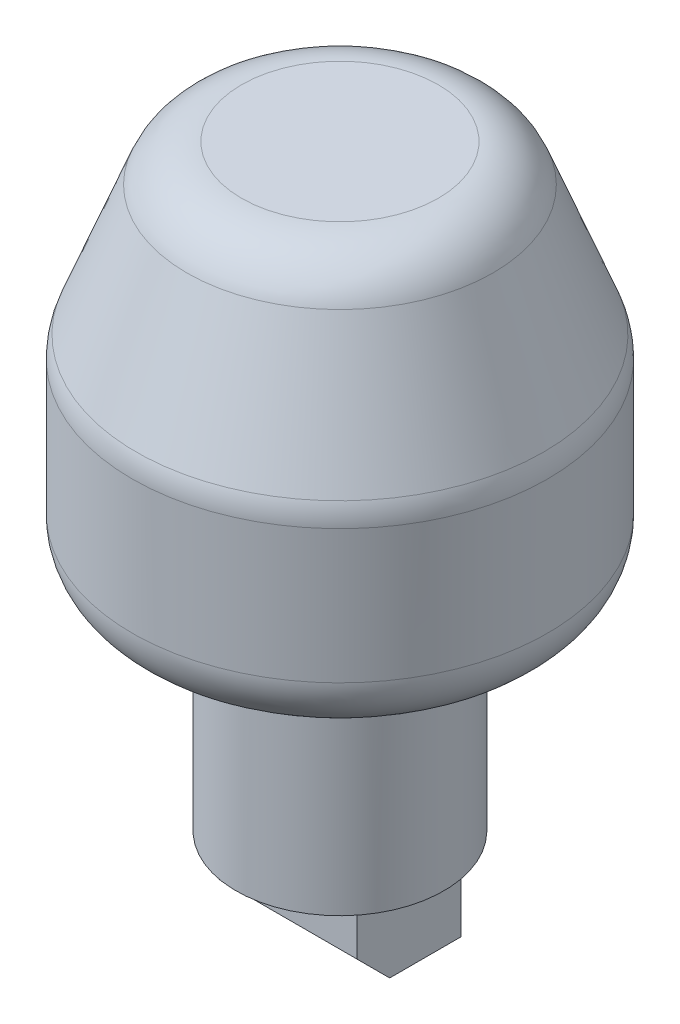
from build123d import *

# Parameters (mm, degrees)
FILLET2_R                = 6.35
BOSS_EXTRUDE1_DEPTH      = 7.4549
SKETCH3_W                = 4.78028
SKETCH3_H                = 7.4422
SKETCH3_W_2              = 4.84124
CUT_EXTRUDE1_DEPTH       = 2.54
BOSS_EXTRUDE2_REACH      = 88.307
BOSS_EXTRUDE2_END_RADIUS = 11.2395
BOSS_EXTRUDE2_START      = 14.29512
SKETCH4_W                = 3.556
SKETCH4_H                = 2.1844


with BuildPart() as part:
    # Sketch1 → Revolve1 (revolve)
    with BuildSketch(Plane.XY):
        Polygon((0, 0), (11.2395, 0), (11.2395, 23.4188), (22.473370688, 23.4188), (22.473370688, 45.4152), (14.986, 64.619312752), (0, 64.619312752), align=None)
    revolve(axis=Axis((0, 64.619312752, 0), (0, -1, 0)))

    # Fillet2
    fillet2_edges = [part.edges().sort_by_distance(p)[0] for p in [
        (-22.473370688, 23.4188, 0),
        (-22.473370688, 45.4152, 0),
        (-14.986, 64.619312752, 0),
    ]]
    fillet(fillet2_edges, radius=FILLET2_R)

    # Sketch2 → Boss-Extrude1 (add, symmetric)
    with BuildSketch(Plane(origin=(0, 0, 0), x_dir=(0, 0, -1), z_dir=(1, 0, 0))):
        Polygon((5.626190712, 0), (-5.626190712, 0), (-5.626190712, -5.461), (-2.070009288, -9.017181424), (5.626190712, -9.017181424), align=None)
    extrude(amount=BOSS_EXTRUDE1_DEPTH, both=True)

    # Sketch3 → Cut-Extrude1 (cut)
    with BuildSketch(Plane.XZ.offset(9.017181424)):
        with Locations((-4.93776, -1.778090712)):
            Rectangle(SKETCH3_W, SKETCH3_H)
        with Locations((0, -1.778090712)):
            Rectangle(SKETCH3_W_2, SKETCH3_H)
        with Locations((4.93776, -1.778090712)):
            Rectangle(SKETCH3_W, SKETCH3_H)
    extrude(amount=-CUT_EXTRUDE1_DEPTH, mode=Mode.SUBTRACT)

    # Boss-Extrude2: up to this cylinder (the profile starts outside it)
    boss_extrude2_end = Plane(origin=(0, 22.3266, 0), z_dir=(0, 1, 0)) * Cylinder(BOSS_EXTRUDE2_END_RADIUS, 200.093, mode=Mode.PRIVATE)
    # Sketch4 → Boss-Extrude2 (add, up to the surface)
    with BuildSketch(Plane.XY.offset(BOSS_EXTRUDE2_START), mode=Mode.PRIVATE) as boss_extrude2_sk1:
        with Locations((0, 22.3266)):
            Rectangle(SKETCH4_W, SKETCH4_H)
    boss_extrude2_tool1 = extrude(boss_extrude2_sk1.sketch, amount=-BOSS_EXTRUDE2_REACH, mode=Mode.PRIVATE) - boss_extrude2_end
    add(boss_extrude2_tool1.solids().sort_by_distance((0, 22.3266, 14.29512))[0])


solid = part.part
